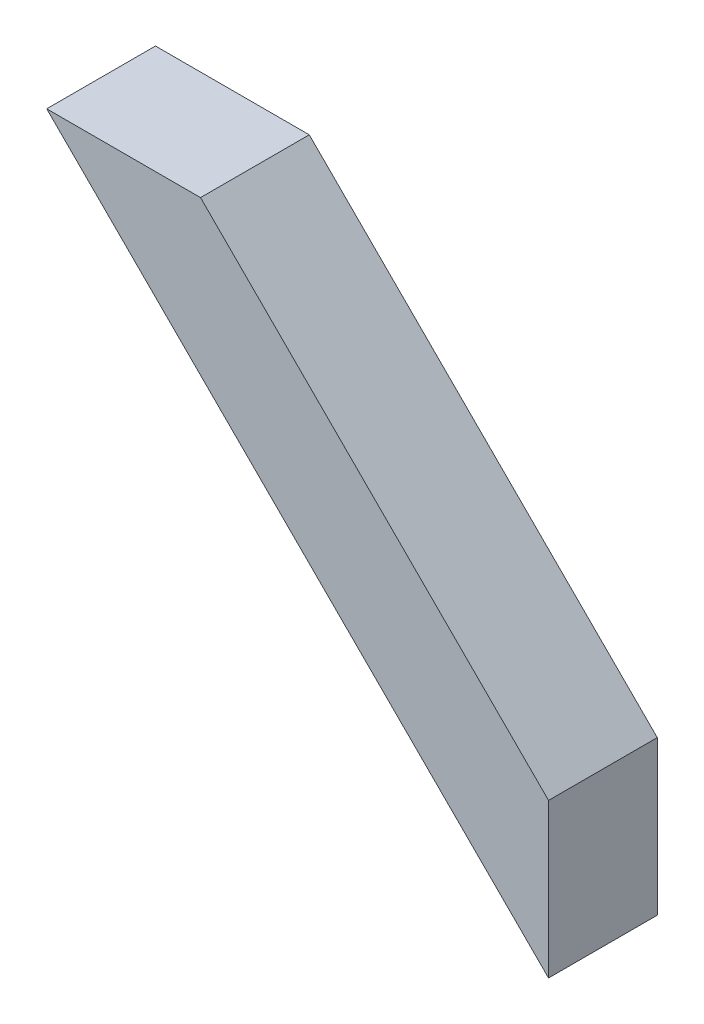
from build123d import *

# Parameters (mm, degrees)
SALIENTE_EXTRUIR1_DEPTH = 63.5


with BuildPart() as part:
    # Croquis1 → Saliente-Extruir1 (new body)
    with BuildSketch(Plane.XY):
        Polygon((-203.2, 203.2), (0, 0), (0, -89.802561211), (-293.002561211, 203.2), align=None)
    extrude(amount=SALIENTE_EXTRUIR1_DEPTH)


solid = part.part
